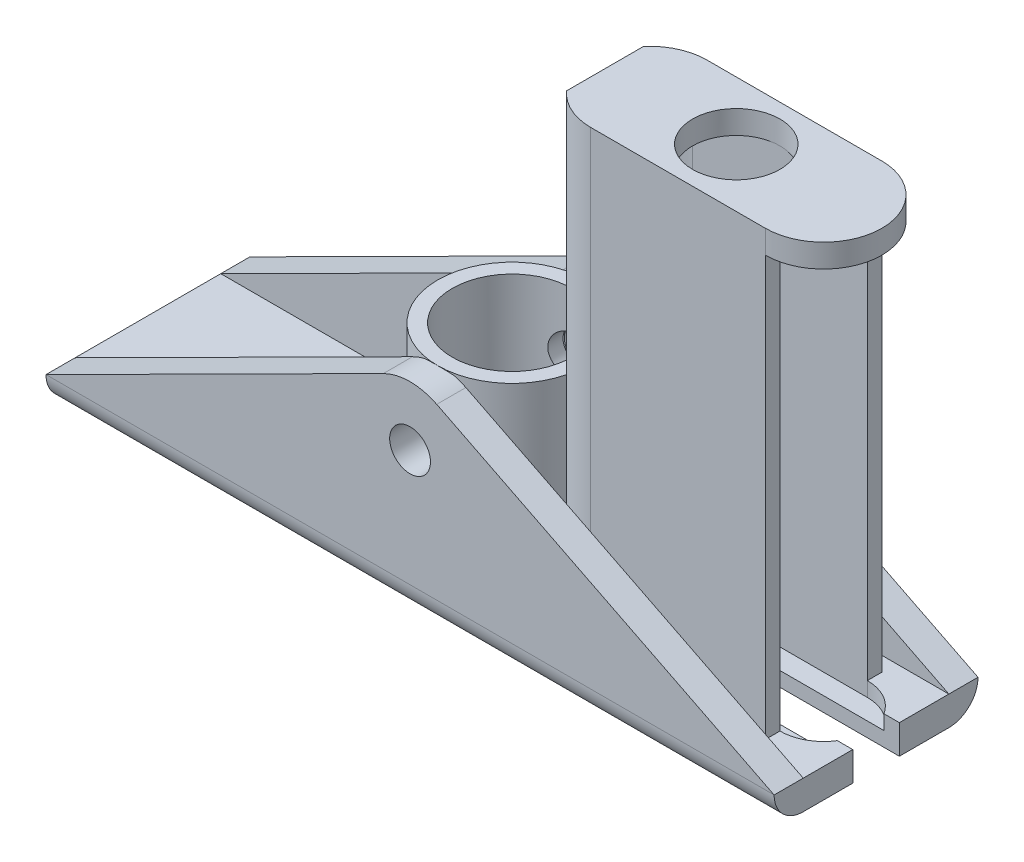
from build123d import *

# Parameters (mm, degrees)
SKETCH2_W                       = 125
SKETCH2_H                       = 35
SKETCH2_R                       = 10
BOSS_EXTRUDE1_DEPTH             = 5
BOSS_EXTRUDE3_REACH             = 19.5
BOSS_EXTRUDE3_DIRECTION_2_REACH = 19.5
CUT_EXTRUDE2_DEPTH              = 12.5
CUT_EXTRUDE2_DEPTH_BACK         = 12.5
SKETCH8_R                       = 12.75
SKETCH8_R_2                     = 10.25
BOSS_EXTRUDE4_DEPTH             = 30.2
FILLET1_R                       = 5
SKETCH9_R                       = 3.5
CUT_EXTRUDE3_DEPTH              = 36.0000001
SKETCH13_R                      = 2
CUT_EXTRUDE5_DEPTH              = 2.5
CUT_EXTRUDE6_DEPTH              = 6
BOSS_EXTRUDE7_DEPTH             = 72
SKETCH17_R                      = 7.5
BOSS_EXTRUDE8_DEPTH             = 4
SKETCH18_R                      = 10.25
BOSS_EXTRUDE9_DEPTH             = 9.5


with BuildPart() as part:
    # Sketch2 → Boss-Extrude1 (new body)
    with BuildSketch(Plane(origin=(0, 0, 0), x_dir=(1, 0, 0), z_dir=(0, 1, 0))):
        Rectangle(SKETCH2_W, SKETCH2_H)
        with Locations((-25, 0)):
            Circle(SKETCH2_R, mode=Mode.SUBTRACT)
    extrude(amount=BOSS_EXTRUDE1_DEPTH)

    # Boss-Extrude3: up to this face of the body (flat: up to its plane)
    boss_extrude3_end = Plane(part.part.faces().sort_by_distance((0, 2.5, -17.5))[0])
    # Sketch6 → Boss-Extrude3 (add, up to the picked face)
    with BuildSketch(Plane.XY, mode=Mode.PRIVATE) as boss_extrude3_sk1:
        with BuildLine():
            Line((-62.5, 5), (-4.580943715, 34.11344911))
            ThreePointArc((-4.580943715, 34.11344911), (0, 35.2), (4.580943715, 34.11344911))
            Line((4.580943715, 34.11344911), (62.5, 5))
            Line((62.5, 5), (-62.5, 5))
        make_face()
    boss_extrude3_tool1 = split(extrude(boss_extrude3_sk1.sketch, amount=-BOSS_EXTRUDE3_REACH, mode=Mode.PRIVATE), bisect_by=boss_extrude3_end, keep=Keep.BOTH, mode=Mode.PRIVATE)
    add(boss_extrude3_tool1.solids().sort_by_distance((0, 15.43289, 0))[0])

    # Boss-Extrude3 direction 2: up to this face of the body (flat: up to its plane)
    boss_extrude3_direction_2_end = Plane(part.part.faces().sort_by_distance((0, 2.5, 17.5))[0])
    # Sketch6 → Boss-Extrude3 direction 2 (add, up to the picked face)
    with BuildSketch(Plane.XY, mode=Mode.PRIVATE) as boss_extrude3_direction_2_sk1:
        with BuildLine():
            Line((-62.5, 5), (-4.580943715, 34.11344911))
            ThreePointArc((-4.580943715, 34.11344911), (0, 35.2), (4.580943715, 34.11344911))
            Line((4.580943715, 34.11344911), (62.5, 5))
            Line((62.5, 5), (-62.5, 5))
        make_face()
    boss_extrude3_direction_2_tool1 = split(extrude(boss_extrude3_direction_2_sk1.sketch, amount=BOSS_EXTRUDE3_DIRECTION_2_REACH, mode=Mode.PRIVATE), bisect_by=boss_extrude3_direction_2_end, keep=Keep.BOTH, mode=Mode.PRIVATE)
    add(boss_extrude3_direction_2_tool1.solids().sort_by_distance((0, 15.43289, 0))[0])

    # Sketch7 → Cut-Extrude2 (cut, two sides)
    with BuildSketch(Plane.XY) as cut_extrude2_sk:
        with BuildLine():
            Line((4.580943715, 34.11344911), (62.5, 5))
            Line((62.5, 5), (-62.5, 5))
            Line((-62.5, 5), (-4.580943715, 34.11344911))
            ThreePointArc((-4.580943715, 34.11344911), (0, 35.2), (4.580943715, 34.11344911))
        make_face()
    extrude(amount=CUT_EXTRUDE2_DEPTH, mode=Mode.SUBTRACT)
    extrude(cut_extrude2_sk.sketch, amount=-CUT_EXTRUDE2_DEPTH_BACK, mode=Mode.SUBTRACT)

    # Sketch8 → Boss-Extrude4 (add)
    with BuildSketch(Plane(origin=(0, 5, 0), x_dir=(1, 0, 0), z_dir=(0, 1, 0))):
        Circle(SKETCH8_R)
        Circle(SKETCH8_R_2, mode=Mode.SUBTRACT)
    extrude(amount=BOSS_EXTRUDE4_DEPTH)

    # Fillet1
    fillet1_edges = [part.edges().sort_by_distance(p)[0] for p in [
        (0, 0, -17.5),
        (0, 0, 17.5),
    ]]
    fillet(fillet1_edges, radius=FILLET1_R)

    # Sketch9 → Cut-Extrude3 (cut, through all)
    with BuildSketch(Plane.XY.offset(17.5)):
        with Locations((0, 25)):
            Circle(SKETCH9_R)
    extrude(amount=-CUT_EXTRUDE3_DEPTH, mode=Mode.SUBTRACT)

    # Sketch13 → Cut-Extrude5 (cut)
    with BuildSketch(Plane(origin=(0, 5, 0), x_dir=(1, 0, 0), z_dir=(0, 1, 0))):
        with BuildLine():
            Line((23.5, 7.5), (53.5, 7.5))
            ThreePointArc((53.5, 7.5), (61, 0), (53.5, -7.5))
            Line((53.5, -7.5), (23.5, -7.5))
            ThreePointArc((23.5, -7.5), (16, 0), (23.5, 7.5))
        make_face()
        with Locations((31.5, 0)):
            Circle(SKETCH13_R, mode=Mode.SUBTRACT)
        with Locations((24.5, 0)):
            Circle(SKETCH13_R, mode=Mode.SUBTRACT)
        with Locations((38.5, 0)):
            Circle(SKETCH13_R, mode=Mode.SUBTRACT)
        with Locations((45.5, 0)):
            Circle(SKETCH13_R, mode=Mode.SUBTRACT)
        with Locations((52.5, 0)):
            Circle(SKETCH13_R, mode=Mode.SUBTRACT)
    extrude(amount=-CUT_EXTRUDE5_DEPTH, mode=Mode.SUBTRACT)

    # Sketch15 → Cut-Extrude6 (cut, through all)
    with BuildSketch(Plane(origin=(0, 5, 0), x_dir=(1, 0, 0), z_dir=(0, 1, 0))):
        with BuildLine():
            Line((23.5, 4), (53.5, 4))
            Line((53.5, 4), (62.5, 4))
            Line((62.5, 4), (62.5, -4))
            Line((62.5, -4), (53.5, -4))
            Line((53.5, -4), (23.5, -4))
            ThreePointArc((23.5, -4), (19.5, 0), (23.5, 4))
        make_face()
    extrude(amount=-CUT_EXTRUDE6_DEPTH, mode=Mode.SUBTRACT)

    # Sketch16 → Boss-Extrude7 (add)
    with BuildSketch(Plane(origin=(0, 5, 0), x_dir=(1, 0, 0), z_dir=(0, 1, 0))):
        with BuildLine():
            Line((16, -4), (16, -6.614378278))
            ThreePointArc((16, -6.614378278), (19.385621722, -9.114378278), (23.5, -10))
            Line((23.5, -10), (53.5, -10))
            Line((53.5, -10), (53.5, -7.5))
            Line((53.5, -7.5), (23.5, -7.5))
            ThreePointArc((23.5, -7.5), (19.877155813, -6.566962768), (17.15571123, -4))
            Line((17.15571123, -4), (16, -4))
        make_face()
        with BuildLine():
            Line((53.5, 10), (23.5, 10))
            ThreePointArc((23.5, 10), (19.385621722, 9.114378278), (16, 6.614378278))
            Line((16, 6.614378278), (16, 4))
            Line((16, 4), (17.15571123, 4))
            ThreePointArc((17.15571123, 4), (19.877155813, 6.566962768), (23.5, 7.5))
            Line((23.5, 7.5), (53.5, 7.5))
            Line((53.5, 7.5), (53.5, 10))
        make_face()
    extrude(amount=BOSS_EXTRUDE7_DEPTH)

    # Sketch17 → Boss-Extrude8 (add)
    with BuildSketch(Plane(origin=(0, 77, 0), x_dir=(1, 0, 0), z_dir=(0, 1, 0))):
        with BuildLine():
            Line((23.5, -10), (53.5, -10))
            ThreePointArc((53.5, -10), (63.5, 0), (53.5, 10))
            Line((53.5, 10), (23.5, 10))
            ThreePointArc((23.5, 10), (19.385621722, 9.114378278), (16, 6.614378278))
            Line((16, 6.614378278), (16, 4))
            Line((16, 4), (16, -4))
            Line((16, -4), (16, -6.614378278))
            ThreePointArc((16, -6.614378278), (19.385621722, -9.114378278), (23.5, -10))
        make_face()
        with Locations((38.5, 0)):
            Circle(SKETCH17_R, mode=Mode.SUBTRACT)
    extrude(amount=BOSS_EXTRUDE8_DEPTH)

    # Sketch18 → Boss-Extrude9 (add)
    with BuildSketch(Plane(origin=(0, 5, 0), x_dir=(1, 0, 0), z_dir=(0, 1, 0))):
        Circle(SKETCH18_R)
    extrude(amount=BOSS_EXTRUDE9_DEPTH)


solid = part.part
